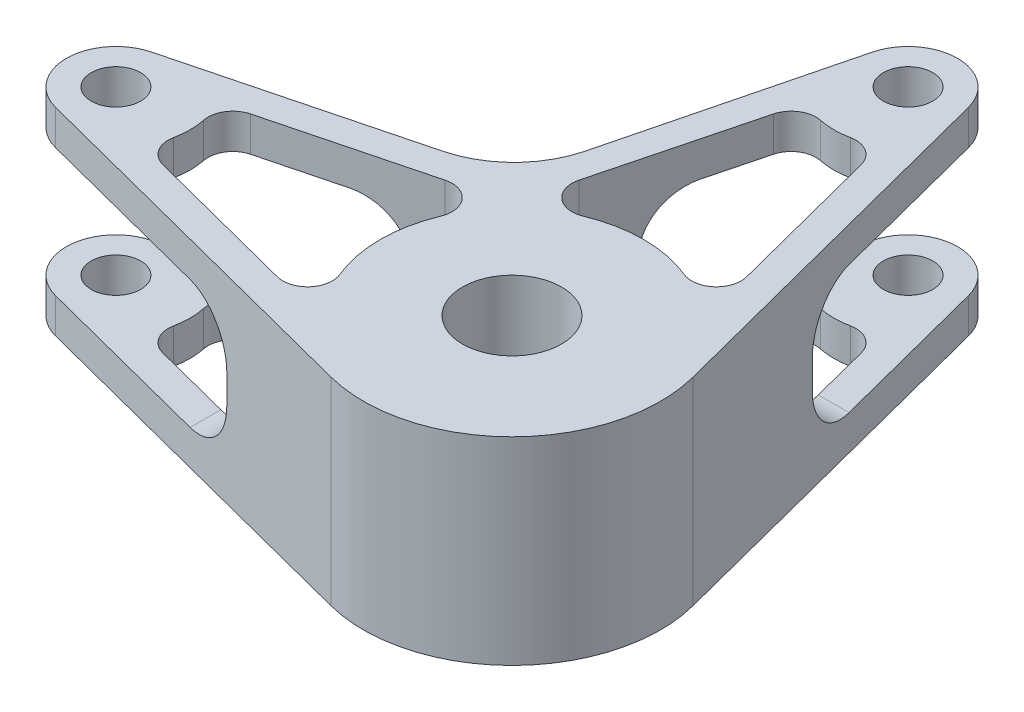
from build123d import *

# Parameters (mm, degrees)
SKETCH1_R               = 5
SKETCH1_R_2             = 2.5
BOSS_EXTRUDE1_DEPTH     = 20
CUT_EXTRUDE1_DEPTH      = 73.947048844
CUT_EXTRUDE1_DEPTH_BACK = 73.947048844
CUT_EXTRUDE2_DEPTH      = 87.382039929
CUT_EXTRUDE2_DEPTH_BACK = 87.382039929
CUT_EXTRUDE3_DEPTH      = 67.708320321
CIRPATTERN1_COUNT       = 2
CIRPATTERN1_ANGLE       = 90


with BuildPart() as part:
    # Sketch1 → Boss-Extrude1 (new body)
    with BuildSketch(Plane(origin=(0, 0, 0), x_dir=(1, 0, 0), z_dir=(0, 1, 0))):
        with BuildLine():
            Line((-41.25, -4.841229183), (-3.75, -14.523687548))
            ThreePointArc((-3.75, -14.523687548), (10.606601718, -10.606601718), (14.523687548, 3.75))
            Line((14.523687548, 3.75), (4.841229183, 41.25))
            ThreePointArc((4.841229183, 41.25), (-0.014355404, 44.999979392), (-4.848327042, 41.222180386))
            Line((-4.848327042, 41.222180386), (-10.709838692, 17.969863651))
            ThreePointArc((-10.709838692, 17.969863651), (-13.330617196, 13.456564929), (-17.868360534, 10.878342533))
            Line((-17.868360534, 10.878342533), (-41.25, 4.841229183))
            ThreePointArc((-41.25, 4.841229183), (-45, 0), (-41.25, -4.841229183))
        make_face()
        with Locations(Location((0, 0, 0), (0, 0, 270))):
            Circle(SKETCH1_R, mode=Mode.SUBTRACT)
        with Locations(Location((0, 40, 0), (0, 0, 270))):
            Circle(SKETCH1_R_2, mode=Mode.SUBTRACT)
        with Locations(Location((-40, 0, 0), (0, 0, 270))):
            Circle(SKETCH1_R_2, mode=Mode.SUBTRACT)
    extrude(amount=BOSS_EXTRUDE1_DEPTH)

    # 3DSketch4 → Cut-Extrude1 (cut, two sides)
    with BuildSketch(Plane(origin=(0, 16.470335, -40), x_dir=(0, -0.36901261681753356, 0.9294243856438652), z_dir=(1, 0, 0))) as cut_extrude1_sk:
        with BuildLine():
            Line((0, 0), (13.941365785, -5.535189252))
            ThreePointArc((13.941365785, -5.535189252), (17.767783679, -5.478735371), (20.433550797, -2.733130408))
            Line((20.433550797, -2.733130408), (21.518695129, 0))
            ThreePointArc((21.518695129, 0), (21.462241248, 3.826417894), (18.716636285, 6.492185012))
            Line((18.716636285, 6.492185012), (4.7752705, 12.027374265))
            Line((4.7752705, 12.027374265), (-8.558795166, 17.321445025))
            Line((-8.558795166, 17.321445025), (-13.334065667, 5.294070761))
            Line((-13.334065667, 5.294070761), (0, 0))
        make_face()
    extrude(amount=CUT_EXTRUDE1_DEPTH, mode=Mode.SUBTRACT)
    extrude(cut_extrude1_sk.sketch, amount=-CUT_EXTRUDE1_DEPTH_BACK, mode=Mode.SUBTRACT)

    # 3DSketch5 → Cut-Extrude2 (cut, two sides)
    with BuildSketch(Plane(origin=(-56.872003502, 16.470335, 0), x_dir=(0.9798226496463329, -0.1998688951288811, 0), z_dir=(0, 0, -1))) as cut_extrude2_sk:
        with BuildLine():
            Line((0, 0), (33.243187397, -6.781103844))
            ThreePointArc((33.243187397, -6.781103844), (37.000084817, -6.052830051), (39.141645121, -2.881335071))
            Line((39.141645121, -2.881335071), (39.729393585, 0))
            ThreePointArc((39.729393585, 0), (39.001119792, 3.75689742), (35.829624813, 5.898457724))
            Line((35.829624813, 5.898457724), (2.586437415, 12.679561568))
            Line((2.586437415, 12.679561568), (0, 0))
        make_face()
    extrude(amount=CUT_EXTRUDE2_DEPTH, mode=Mode.SUBTRACT)
    extrude(cut_extrude2_sk.sketch, amount=-CUT_EXTRUDE2_DEPTH_BACK, mode=Mode.SUBTRACT)

    # Sketch2 → Cut-Extrude3 (cut, through all)
    with BuildSketch(Plane(origin=(0, 20, 0), x_dir=(1, 0, 0), z_dir=(0, 1, 0))):
        with BuildLine():
            Line((-30.589723784, 4.495313989), (-17.164379291, 7.962110305))
            Line((-17.164379291, 7.962110305), (-15.226453583, 8.462536474))
            ThreePointArc((-15.226453583, 8.462536474), (-12.714609551, 7.682081043), (-12.291345207, 5.086061319))
            ThreePointArc((-12.291345207, 5.086061319), (-13.302074527, 0), (-12.291345207, -5.086061319))
            ThreePointArc((-12.291345207, -5.086061319), (-12.714609551, -7.682081043), (-15.226453583, -8.462536474))
            Line((-15.226453583, -8.462536474), (-17.164379291, -7.962110305))
            Line((-17.164379291, -7.962110305), (-30.589723784, -4.495313989))
            Line((-30.589723784, -4.495313989), (-30.829716392, -4.433341241))
            ThreePointArc((-30.829716392, -4.433341241), (-32.325817378, -3.33586596), (-32.653488198, -1.509557665))
            ThreePointArc((-32.653488198, -1.509557665), (-32.5, 0), (-32.653488198, 1.509557665))
            ThreePointArc((-32.653488198, 1.509557665), (-32.325817378, 3.33586596), (-30.829716392, 4.433341241))
            Line((-30.829716392, 4.433341241), (-30.589723784, 4.495313989))
        make_face()
    cut_extrude3 = extrude(amount=-CUT_EXTRUDE3_DEPTH, mode=Mode.SUBTRACT)

    # CirPattern1: Cut-Extrude3 ×2 about axis
    cirpattern1_axis = Axis((0, 0, 0), (0, -1, 0))
    for i in range(1, CIRPATTERN1_COUNT):
        add(cut_extrude3.rotate(cirpattern1_axis, i * CIRPATTERN1_ANGLE / (CIRPATTERN1_COUNT - 1)), mode=Mode.SUBTRACT)


solid = part.part
